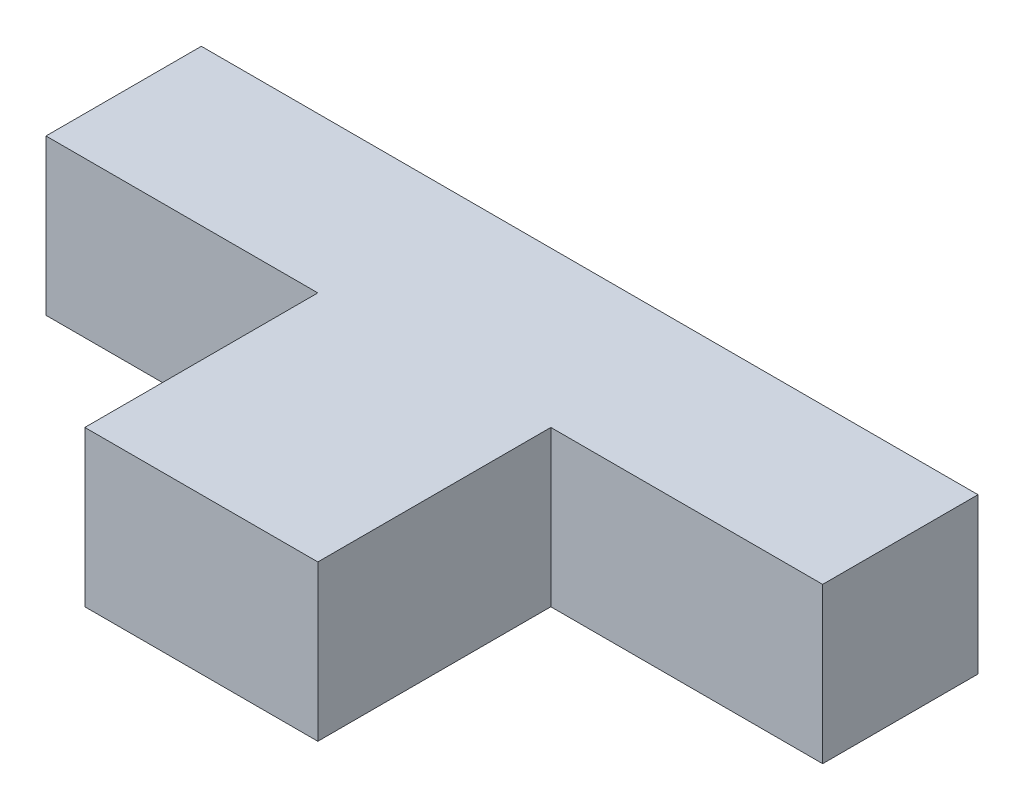
from build123d import *

# Parameters (mm, degrees)
SKETCH1_W           = 76.2
SKETCH1_H           = 76.2
SKETCH1_H_2         = 25.4
BOSS_EXTRUDE1_DEPTH = 50.8


with BuildPart() as part:
    # Sketch1 → Boss-Extrude1 (new body)
    with BuildSketch(Plane(origin=(0, 0, 0), x_dir=(1, 0, 0), z_dir=(0, 1, 0))):
        Polygon((38.1, 50.8), (38.1, 25.4), (127, 25.4), (127, 76.2), (-127, 76.2), (-127, 25.4), (-38.1, 25.4), (-38.1, 50.8), align=None)
        with Locations((0, -12.7)):
            Rectangle(SKETCH1_W, SKETCH1_H)
        with Locations((0, 38.1)):
            Rectangle(SKETCH1_W, SKETCH1_H_2)
    extrude(amount=BOSS_EXTRUDE1_DEPTH)


solid = part.part
